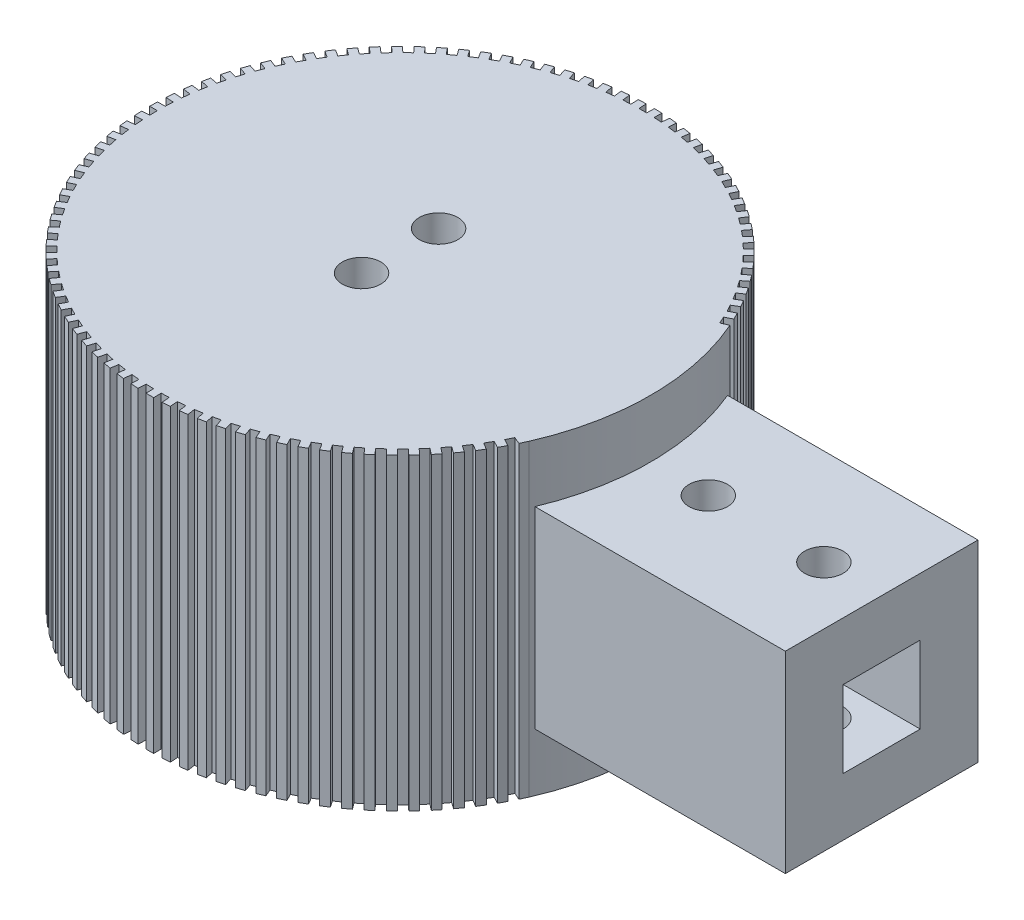
from build123d import *

# Parameters (mm, degrees)
SKETCH1_R               = 32.5
BOSS_EXTRUDE1_DEPTH     = 40
SKETCH2_W               = 10
SKETCH2_H               = 10
BOSS_EXTRUDE2_DEPTH     = 62.5
SKETCH3_R               = 2.5
CUT_EXTRUDE1_DEPTH      = 1
CUT_EXTRUDE1_DEPTH_BACK = 41
SKETCH4_R               = 2.5
CUT_EXTRUDE2_DEPTH      = 8.5
CUT_EXTRUDE2_DEPTH_BACK = 33.5
CUT_EXTRUDE3_DEPTH      = 41


with BuildPart() as part:
    # Sketch1 → Boss-Extrude1 (new body)
    with BuildSketch(Plane(origin=(0, 0, 0), x_dir=(1, 0, 0), z_dir=(0, 1, 0))):
        Circle(SKETCH1_R)
    extrude(amount=BOSS_EXTRUDE1_DEPTH)

    # Sketch2 → Boss-Extrude2 (add)
    with BuildSketch(Plane(origin=(0, 0, 0), x_dir=(0, 0, -1), z_dir=(1, 0, 0))):
        Polygon((0, 32.5), (-12.5, 32.5), (-12.5, 7.5), (12.5, 7.5), (12.5, 32.5), align=None)
        with Locations((0, 20)):
            Rectangle(SKETCH2_W, SKETCH2_H, mode=Mode.SUBTRACT)
    extrude(amount=BOSS_EXTRUDE2_DEPTH)

    # Sketch3 → Cut-Extrude1 (cut, two sides)
    with BuildSketch(Plane(origin=(0, 40, 0), x_dir=(1, 0, 0), z_dir=(0, 1, 0))) as cut_extrude1_sk:
        with Locations((0, 5)):
            Circle(SKETCH3_R)
        with Locations((0, -5)):
            Circle(SKETCH3_R)
    extrude(amount=CUT_EXTRUDE1_DEPTH, mode=Mode.SUBTRACT)
    extrude(cut_extrude1_sk.sketch, amount=-CUT_EXTRUDE1_DEPTH_BACK, mode=Mode.SUBTRACT)

    # Sketch4 → Cut-Extrude2 (cut, two sides)
    with BuildSketch(Plane(origin=(0, 32.5, 0), x_dir=(1, 0, 0), z_dir=(0, 1, 0))) as cut_extrude2_sk:
        with Locations((40, 0)):
            Circle(SKETCH4_R)
        with Locations((55, 0)):
            Circle(SKETCH4_R)
    extrude(amount=CUT_EXTRUDE2_DEPTH, mode=Mode.SUBTRACT)
    extrude(cut_extrude2_sk.sketch, amount=-CUT_EXTRUDE2_DEPTH_BACK, mode=Mode.SUBTRACT)

    # Sketch5 → Cut-Extrude3 (cut, through all)
    with BuildSketch(Plane(origin=(0, 40, 0), x_dir=(1, 0, 0), z_dir=(0, 1, 0))):
        with BuildLine():
            Line((-31.5, 0), (-32.494865573, 0))
            Line((-32.494865573, 0), (-32.479474882, 1))
            Line((-32.479474882, 1), (-31.484122983, 1))
            Line((-31.484122983, 1), (-31.436580309, 1.997853469))
            Line((-31.436580309, 1.997853469), (-32.429442895, 2.060951743))
            Line((-32.429442895, 2.060951743), (-32.350659271, 3.057962282))
            Line((-32.350659271, 3.057962282), (-31.357311338, 2.994833163))
            Line((-31.357311338, 2.994833163), (-31.246576604, 3.987662288))
            Line((-31.246576604, 3.987662288), (-32.233438297, 4.113604761))
            Line((-32.233438297, 4.113604761), (-32.091578973, 5.103611229))
            Line((-32.091578973, 5.103611229), (-31.104234867, 4.97760719))
            Line((-31.104234867, 4.97760719), (-30.930753964, 5.961414197))
            Line((-30.930753964, 5.961414197), (-31.90764102, 6.149693745))
            Line((-31.90764102, 6.149693745), (-31.703277214, 7.128709735))
            Line((-31.703277214, 7.128709735), (-30.725912621, 6.940338149))
            Line((-30.725912621, 6.940338149), (-30.490384094, 7.911161596))
            Line((-30.490384094, 7.911161596), (-31.453362933, 8.161020082))
            Line((-31.453362933, 8.161020082), (-31.187317547, 9.125103443))
            Line((-31.187317547, 9.125103443), (-30.223867969, 8.875122817))
            Line((-30.223867969, 8.875122817), (-29.927240209, 9.82905354))
            Line((-29.927240209, 9.82905354), (-30.872433255, 10.139484872))
            Line((-30.872433255, 10.139484872), (-30.545777559, 11.08475358))
            Line((-30.545777559, 11.08475358), (-29.600122468, 10.774170497))
            Line((-29.600122468, 10.774170497), (-29.24358989, 11.707367353))
            Line((-29.24358989, 11.707367353), (-30.167191185, 12.077121535))
            Line((-30.167191185, 12.077121535), (-29.781240506, 12.999769326))
            Line((-29.781240506, 12.999769326), (-28.857187721, 12.629834395))
            Line((-28.857187721, 12.629834395), (-28.442185956, 13.538539731))
            Line((-28.442185956, 13.538539731), (-29.340476484, 13.966127892))
            Line((-29.340476484, 13.966127892), (-28.896784908, 14.86243959))
            Line((-28.896784908, 14.86243959), (-27.998055264, 14.434642408))
            Line((-27.998055264, 14.434642408), (-27.526255378, 15.315197187))
            Line((-27.526255378, 15.315197187), (-28.395618039, 15.798897581))
            Line((-28.395618039, 15.798897581), (-27.895972157, 16.665264055))
            Line((-27.895972157, 16.665264055), (-27.02618452, 16.18132721))
            Line((-27.02618452, 16.18132721), (-26.499486284, 17.03018575))
            Line((-26.499486284, 17.03018575), (-27.336420462, 17.568050686))
            Line((-27.336420462, 17.568050686), (-26.782832171, 18.400983383))
            Line((-26.782832171, 18.400983383), (-25.94548887, 17.862855519))
            Line((-25.94548887, 17.862855519), (-25.366013112, 18.676599765))
            Line((-25.366013112, 18.676599765), (-26.167148768, 19.266463452))
            Line((-26.167148768, 19.266463452), (-25.561847173, 20.062608446))
            Line((-25.561847173, 20.062608446), (-24.760319893, 19.472456413))
            Line((-24.760319893, 19.472456413), (-24.130399958, 20.247809705))
            Line((-24.130399958, 20.247809705), (-24.892511202, 20.887296969))
            Line((-24.892511202, 20.887296969), (-24.237933639, 21.643448466))
            Line((-24.237933639, 21.643448466), (-23.475449848, 21.003648598))
            Line((-23.475449848, 21.003648598), (-22.7976222, 21.737488862))
            Line((-22.7976222, 21.737488862), (-23.517640279, 22.424024713))
            Line((-23.517640279, 22.424024713), (-22.8164225, 23.137137958))
            Line((-22.8164225, 23.137137958), (-22.096052451, 22.450266504))
            Line((-22.096052451, 22.450266504), (-21.373046464, 23.139638823))
            Line((-21.373046464, 23.139638823), (-22.048072118, 23.870458824))
            Line((-22.048072118, 23.870458824), (-21.303037681, 24.537662361))
            Line((-21.303037681, 24.537662361), (-20.62768205, 23.806485109))
            Line((-20.62768205, 23.806485109), (-19.862409013, 24.448613625))
            Line((-19.862409013, 24.448613625), (-20.489724153, 25.220775022))
            Line((-20.489724153, 25.220775022), (-19.703873048, 25.839382259))
            Line((-19.703873048, 25.839382259), (-19.076251253, 25.066843402))
            Line((-19.076251253, 25.066843402), (-18.271792651, 25.65914249))
            Line((-18.271792651, 25.65914249), (-18.848871301, 26.469536061))
            Line((-18.848871301, 26.469536061), (-18.025367872, 27.037056083))
            Line((-18.025367872, 27.037056083), (-17.448007126, 26.226266363))
            Line((-17.448007126, 26.226266363), (-16.60760223, 26.766351043))
            Line((-16.60760223, 26.766351043), (-17.132120697, 27.61171362))
            Line((-17.132120697, 27.61171362), (-16.274280902, 28.125861226))
            Line((-16.274280902, 28.125861226), (-15.749506032, 27.280085406))
            Line((-15.749506032, 27.280085406), (-14.876538855, 27.765780949))
            Line((-14.876538855, 27.765780949), (-15.346385089, 28.642708554))
            Line((-15.346385089, 28.642708554), (-14.457663147, 29.101413452))
            Line((-14.457663147, 29.101413452), (-13.987587236, 28.224057173))
            Line((-13.987587236, 28.224057173), (-13.08557291, 28.653407854))
            Line((-13.08557291, 28.653407854), (-13.498855004, 29.55836941))
            Line((-13.498855004, 29.55836941), (-12.582829485, 29.959784558))
            Line((-12.582829485, 29.959784558), (-12.169345363, 29.054380624))
            Line((-12.169345363, 29.054380624), (-11.24191598, 29.425657598))
            Line((-11.24191598, 29.425657598), (-11.596969795, 30.355009144))
            Line((-11.596969795, 30.355009144), (-10.65732921, 30.697518185))
            Line((-10.65732921, 30.697518185), (-10.302101831, 29.767712338))
            Line((-10.302101831, 29.767712338), (-9.352991823, 30.079420605))
            Line((-9.352991823, 30.079420605), (-9.648387682, 31.029419971))
            Line((-9.648387682, 31.029419971), (-8.688915631, 31.311643741))
            Line((-8.688915631, 31.311643741), (-8.393375372, 30.361179982))
            Line((-8.393375372, 30.361179982), (-7.426406469, 30.612064402))
            Line((-7.426406469, 30.612064402), (-7.660954917, 31.578886275))
            Line((-7.660954917, 31.578886275), (-6.685514856, 31.799688359))
            Line((-6.685514856, 31.799688359), (-6.450851752, 30.832393869))
            Line((-6.450851752, 30.832393869), (-5.469917597, 31.02144422))
            Line((-5.469917597, 31.02144422), (-5.64267419, 32.001195549))
            Line((-5.64267419, 32.001195549), (-4.655193872, 32.159686855))
            Line((-4.655193872, 32.159686855), (-4.482352828, 31.179456588))
            Line((-4.482352828, 31.179456588), (-3.491403297, 31.305911631))
            Line((-3.491403297, 31.305911631), (-3.601672406, 32.294647304))
            Line((-3.601672406, 32.294647304), (-2.606128065, 32.390189643))
            Line((-2.606128065, 32.390189643), (-2.495805052, 31.40097064))
            Line((-2.495805052, 31.40097064), (-1.498830348, 31.464321184))
            Line((-1.498830348, 31.464321184), (-1.546167958, 32.458059912))
            Line((-1.546167958, 32.458059912), (-0.546568301, 32.490268569))
            Line((-0.546568301, 32.490268569), (-0.49920755, 31.496044066))
            Line((-0.49920755, 31.496044066), (0.499777861, 31.496035022))
            Line((0.499777861, 31.496035022), (0.515562362, 32.490775368))
            Line((0.515562362, 32.490775368), (1.515192302, 32.459520651))
            Line((1.515192302, 32.459520651), (1.499400084, 31.464294039))
            Line((1.499400084, 31.464294039), (2.496373641, 31.400925442))
            Line((2.496373641, 31.400925442), (2.575216695, 32.39266194))
            Line((2.575216695, 32.39266194), (3.570851759, 32.298069699))
            Line((3.570851759, 32.298069699), (3.491970164, 31.305848405))
            Line((3.491970164, 31.305848405), (4.482917406, 31.179375419))
            Line((4.482917406, 31.179375419), (4.624501539, 32.164114695))
            Line((4.624501539, 32.164114695), (5.612132657, 32.006565821))
            Line((5.612132657, 32.006565821), (5.470479312, 31.021345169))
            Line((5.470479312, 31.021345169), (6.451410044, 30.832277056))
            Line((6.451410044, 30.832277056), (6.655165147, 31.806053912))
            Line((6.655165147, 31.806053912), (7.630815477, 31.586182798))
            Line((7.630815477, 31.586182798), (7.426960771, 30.611929924))
            Line((7.426960771, 30.611929924), (8.393925131, 30.361027995))
            Line((8.393925131, 30.361027995), (8.659030755, 31.319921376))
            Line((8.659030755, 31.319921376), (9.618771697, 31.038613365))
            Line((9.618771697, 31.038613365), (9.35353648, 30.079251242))
            Line((9.35353648, 30.079251242), (10.302640844, 29.76752579))
            Line((10.302640844, 29.76752579), (10.628029501, 30.70767457))
            Line((10.628029501, 30.70767457), (11.567996518, 30.366062391))
            Line((11.567996518, 30.366062391), (11.2424488, 29.425454032))
            Line((11.2424488, 29.425454032), (12.169871459, 29.054160264))
            Line((12.169871459, 29.054160264), (12.554232924, 29.971778797))
            Line((12.554232924, 29.971778797), (13.4706411, 29.571238002))
            Line((13.4706411, 29.571238002), (13.086091745, 28.653170904))
            Line((13.086091745, 28.653170904), (13.988098297, 28.22380389))
            Line((13.988098297, 28.22380389), (14.429884882, 29.11519725))
            Line((14.429884882, 29.11519725), (15.319044164, 28.657340674))
            Line((15.319044164, 28.657340674), (14.877041618, 27.765511569))
            Line((14.877041618, 27.765511569), (15.75, 27.279800219))
            Line((15.75, 27.279800219), (16.247432786, 28.141379079))
            Line((16.247432786, 28.141379079), (17.105762845, 27.628050349))
            Line((17.105762845, 27.628050349), (16.608086895, 26.766050319))
            Line((16.608086895, 26.766050319), (17.448482012, 26.225950421))
            Line((17.448482012, 26.225950421), (17.999558013, 27.054245506))
            Line((17.999558013, 27.054245506), (18.823602655, 26.487511617))
            Line((18.823602655, 26.487511617), (18.272257268, 25.658811631))
            Line((18.272257268, 25.658811631), (19.076705145, 25.066497977))
            Line((19.076705145, 25.066497977), (19.679205373, 25.858174036))
            Line((19.679205373, 25.858174036), (20.465646462, 25.240317024))
            Line((20.465646462, 25.240317024), (19.86285171, 24.448253965))
            Line((19.86285171, 24.448253965), (20.628113119, 23.806111592))
            Line((20.628113119, 23.806111592), (21.279611518, 24.557980825))
            Line((21.279611518, 24.557980825), (22.025282334, 23.891488583))
            Line((22.025282334, 23.891488583), (21.373465459, 23.139251809))
            Line((21.373465459, 23.139251809), (22.096458963, 22.449866398))
            Line((22.096458963, 22.449866398), (22.794332179, 23.158901293))
            Line((22.794332179, 23.158901293), (23.496230167, 22.44645755))
            Line((23.496230167, 22.44645755), (22.798015805, 21.737076053))
            Line((22.798015805, 21.737076053), (23.475830165, 21.003223516))
            Line((23.475830165, 21.003223516), (24.217268108, 21.66656904))
            Line((24.217268108, 21.66656904), (24.872566974, 20.911042554))
            Line((24.872566974, 20.911042554), (24.130766589, 20.247372764))
            Line((24.130766589, 20.247372764), (24.760672484, 19.472008066))
            Line((24.760672484, 19.472008066), (25.542689647, 20.08699316))
            Line((25.542689647, 20.08699316), (26.148750733, 19.291426171))
            Line((26.148750733, 19.291426171), (25.366351292, 18.67614045))
            Line((25.366351292, 18.67614045), (25.945812315, 17.862385712))
            Line((25.945812315, 17.862385712), (26.765259789, 18.426534048))
            Line((26.765259789, 18.426534048), (27.319642701, 17.594130023))
            Line((27.319642701, 17.594130023), (26.499794652, 17.029705911))
            Line((26.499794652, 17.029705911), (27.026477517, 16.180837835))
            Line((27.026477517, 16.180837835), (27.880055677, 16.691877787))
            Line((27.880055677, 16.691877787), (28.380528111, 15.825988524))
            Line((28.380528111, 15.825988524), (27.526532691, 15.314698757))
            Line((27.526532691, 15.314698757), (27.998316633, 14.434135434))
            Line((27.998316633, 14.434135434), (28.88258842, 14.890009225))
            Line((28.88258842, 14.890009225), (29.32713515, 13.994121354))
            Line((29.32713515, 13.994121354), (28.442431099, 13.538024715))
            Line((28.442431099, 13.538024715), (28.857416409, 12.629311865))
            Line((28.857416409, 12.629311865), (29.768821174, 13.028183852))
            Line((29.768821174, 13.028183852), (34.69584289, 15.184471613))
            ThreePointArc((34.69584289, 15.184471613), (-37.873073443, 0), (34.69584289, -15.184471613))
            Line((34.69584289, -15.184471613), (29.768821174, -13.028183852))
            Line((29.768821174, -13.028183852), (29.353791097, -13.938121711))
            Line((29.353791097, -13.938121711), (28.441940804, -13.539054742))
            Line((28.441940804, -13.539054742), (27.998316633, -14.434135434))
            Line((27.998316633, -14.434135434), (28.88258842, -14.890009225))
            Line((28.88258842, -14.890009225), (28.410682107, -15.771792251))
            Line((28.410682107, -15.771792251), (27.525978055, -15.315695613))
            Line((27.525978055, -15.315695613), (27.026477517, -16.180837835))
            Line((27.026477517, -16.180837835), (27.880055677, -16.691877787))
            Line((27.880055677, -16.691877787), (27.353173327, -17.54195535))
            Line((27.353173327, -17.54195535), (26.499177908, -17.030665583))
            Line((26.499177908, -17.030665583), (25.945812315, -17.862385712))
            Line((25.945812315, -17.862385712), (26.765259789, -18.426534048))
            Line((26.765259789, -18.426534048), (26.185522973, -19.241483186))
            Line((26.185522973, -19.241483186), (25.365674924, -18.677059074))
            Line((25.365674924, -18.677059074), (24.760672484, -19.472008066))
            Line((24.760672484, -19.472008066), (25.542689647, -20.08699316))
            Line((25.542689647, -20.08699316), (24.91243276, -20.863532361))
            Line((24.91243276, -20.863532361), (24.13003332, -20.24824664))
            Line((24.13003332, -20.24824664), (23.475830165, -21.003223516))
            Line((23.475830165, -21.003223516), (24.217268108, -21.66656904))
            Line((24.217268108, -21.66656904), (23.539028973, -22.401571454))
            Line((23.539028973, -22.401571454), (22.797228588, -21.737901663))
            Line((22.797228588, -21.737901663), (22.096458963, -22.449866398))
            Line((22.096458963, -22.449866398), (22.794332179, -23.158901293))
            Line((22.794332179, -23.158901293), (22.070841824, -23.849407325))
            Line((22.070841824, -23.849407325), (21.372627463, -23.140025829))
            Line((21.372627463, -23.140025829), (20.628113119, -23.806111592))
            Line((20.628113119, -23.806111592), (21.279611518, -24.557980825))
            Line((21.279611518, -24.557980825), (20.513783185, -25.201210051))
            Line((20.513783185, -25.201210051), (19.86196631, -24.448973277))
            Line((19.86196631, -24.448973277), (19.076705145, -25.066497977))
            Line((19.076705145, -25.066497977), (19.679205373, -25.858174036))
            Line((19.679205373, -25.858174036), (18.874122781, -26.451536398))
            Line((18.874122781, -26.451536398), (18.271328029, -25.659473339))
            Line((18.271328029, -25.659473339), (17.448482012, -26.225950421))
            Line((17.448482012, -26.225950421), (17.999558013, -27.054245506))
            Line((17.999558013, -27.054245506), (17.158462946, -27.595351745))
            Line((17.158462946, -27.595351745), (16.607117559, -26.766651759))
            Line((16.607117559, -26.766651759), (15.75, -27.279800219))
            Line((15.75, -27.279800219), (16.247432786, -28.141379079))
            Line((16.247432786, -28.141379079), (15.373712037, -28.628050349))
            Line((15.373712037, -28.628050349), (14.876036088, -27.766050319))
            Line((14.876036088, -27.766050319), (13.988098297, -28.22380389))
            Line((13.988098297, -28.22380389), (14.429884882, -29.11519725))
            Line((14.429884882, -29.11519725), (13.527056616, -29.545473899))
            Line((13.527056616, -29.545473899), (13.08505407, -28.653644794))
            Line((13.08505407, -28.653644794), (12.169871459, -29.054160264))
            Line((12.169871459, -29.054160264), (12.554232924, -29.971778797))
            Line((12.554232924, -29.971778797), (11.625932511, -30.343928253))
            Line((11.625932511, -30.343928253), (11.241383157, -29.425861155))
            Line((11.241383157, -29.425861155), (10.302640845, -29.76752579))
            Line((10.302640845, -29.76752579), (10.628029501, -30.70767457))
            Line((10.628029501, -30.70767457), (9.67799488, -31.020198318))
            Line((9.67799488, -31.020198318), (9.352447162, -30.079589959))
            Line((9.352447162, -30.079589959), (8.393925131, -30.361027995))
            Line((8.393925131, -30.361027995), (8.659030755, -31.319921376))
            Line((8.659030755, -31.319921376), (7.69108738, -31.571560993))
            Line((7.69108738, -31.571560993), (7.425852163, -30.61219887))
            Line((7.425852163, -30.61219887), (6.451410044, -30.832277056))
            Line((6.451410044, -30.832277056), (6.655165147, -31.806053912))
            Line((6.655165147, -31.806053912), (5.673210585, -31.995796134))
            Line((5.673210585, -31.995796134), (5.469355879, -31.021543261))
            Line((5.469355879, -31.021543261), (4.482917406, -31.179375419))
            Line((4.482917406, -31.179375419), (4.624501539, -32.164114695))
            Line((4.624501539, -32.164114695), (3.632489773, -32.291195497))
            Line((3.632489773, -32.291195497), (3.490836429, -31.305974846))
            Line((3.490836429, -31.305974846), (2.496373641, -31.400925442))
            Line((2.496373641, -31.400925442), (2.575216695, -32.39266194))
            Line((2.575216695, -32.39266194), (1.577142207, -32.456569613))
            Line((1.577142207, -32.456569613), (1.498260612, -31.464348319))
            Line((1.498260612, -31.464348319), (0.499777861, -31.496035022))
            Line((0.499777861, -31.496035022), (0.515562362, -32.490775368))
            Line((0.515562362, -32.490775368), (-0.484555954, -32.491252578))
            Line((-0.484555954, -32.491252578), (-0.500348171, -31.496025967))
            Line((-0.500348171, -31.496025967), (-1.498830348, -31.464321184))
            Line((-1.498830348, -31.464321184), (-1.546167958, -32.458059912))
            Line((-1.546167958, -32.458059912), (-2.544302979, -32.395104737))
            Line((-2.544302979, -32.395104737), (-2.496942229, -31.400880235))
            Line((-2.496942229, -31.400880235), (-3.491403297, -31.305911631))
            Line((-3.491403297, -31.305911631), (-3.601672406, -32.294647304))
            Line((-3.601672406, -32.294647304), (-4.593804994, -32.168513243))
            Line((-4.593804994, -32.168513243), (-4.483481981, -31.17929424))
            Line((-4.483481981, -31.17929424), (-5.469917597, -31.02144422))
            Line((-5.469917597, -31.02144422), (-5.64267419, -32.001195549))
            Line((-5.64267419, -32.001195549), (-6.624809378, -31.8123905))
            Line((-6.624809378, -31.8123905), (-6.451968334, -30.832160233))
            Line((-6.451968334, -30.832160233), (-7.426406469, -30.612064402))
            Line((-7.426406469, -30.612064402), (-7.660954917, -31.578886275))
            Line((-7.660954917, -31.578886275), (-8.629137992, -31.328170488))
            Line((-8.629137992, -31.328170488), (-8.394474888, -30.360875998))
            Line((-8.394474888, -30.360875998), (-9.352991823, -30.079420605))
            Line((-9.352991823, -30.079420605), (-9.648387682, -31.029419971))
            Line((-9.648387682, -31.029419971), (-10.598720114, -30.71780299))
            Line((-10.598720114, -30.71780299), (-10.303179854, -29.767339231))
            Line((-10.303179854, -29.767339231), (-11.24191598, -29.425657598))
            Line((-11.24191598, -29.425657598), (-11.596969795, -30.355009144))
            Line((-11.596969795, -30.355009144), (-12.52562493, -29.983745742))
            Line((-12.52562493, -29.983745742), (-12.170397552, -29.053939895))
            Line((-12.170397552, -29.053939895), (-13.08557291, -28.653407854))
            Line((-13.08557291, -28.653407854), (-13.498855004, -29.55836941))
            Line((-13.498855004, -29.55836941), (-14.402093476, -29.128954532))
            Line((-14.402093476, -29.128954532), (-13.988609354, -28.223550598))
            Line((-13.988609354, -28.223550598), (-14.876538855, -27.765780949))
            Line((-14.876538855, -27.765780949), (-15.346385089, -28.642708554))
            Line((-15.346385089, -28.642708554), (-16.220569874, -28.156871303))
            Line((-16.220569874, -28.156871303), (-15.750493963, -27.279515024))
            Line((-15.750493963, -27.279515024), (-16.60760223, -26.766351043))
            Line((-16.60760223, -26.766351043), (-17.132120697, -27.61171362))
            Line((-17.132120697, -27.61171362), (-17.973731762, -27.071410291))
            Line((-17.973731762, -27.071410291), (-17.448956892, -26.225634471))
            Line((-17.448956892, -26.225634471), (-18.271792651, -25.65914249))
            Line((-18.271792651, -25.65914249), (-18.848871301, -26.469536061))
            Line((-18.848871301, -26.469536061), (-19.654519776, -25.876942264))
            Line((-19.654519776, -25.876942264), (-19.07715903, -25.066152544))
            Line((-19.07715903, -25.066152544), (-19.862409013, -24.448613625))
            Line((-19.862409013, -24.448613625), (-20.489724153, -25.220775022))
            Line((-20.489724153, -25.220775022), (-21.256165976, -24.578276924))
            Line((-21.256165976, -24.578276924), (-20.628544182, -23.805738067))
            Line((-20.628544182, -23.805738067), (-21.373046464, -23.139638823))
            Line((-21.373046464, -23.139638823), (-22.048072118, -23.870458824))
            Line((-22.048072118, -23.870458824), (-22.772221098, -23.180643538))
            Line((-22.772221098, -23.180643538), (-22.096865467, -22.449466286))
            Line((-22.096865467, -22.449466286), (-22.7976222, -21.737488862))
            Line((-22.7976222, -21.737488862), (-23.517640279, -22.424024713))
            Line((-23.517640279, -22.424024713), (-24.196580523, -21.689669882))
            Line((-24.196580523, -21.689669882), (-23.476210474, -21.002798427))
            Line((-23.476210474, -21.002798427), (-24.130399958, -20.247809705))
            Line((-24.130399958, -20.247809705), (-24.892511202, -20.887296969))
            Line((-24.892511202, -20.887296969), (-25.523508858, -20.11135958))
            Line((-25.523508858, -20.11135958), (-24.761025067, -19.471559712))
            Line((-24.761025067, -19.471559712), (-25.366013112, -18.676599765))
            Line((-25.366013112, -18.676599765), (-26.167148768, -19.266463452))
            Line((-26.167148768, -19.266463452), (-26.747663031, -18.452067931))
            Line((-26.747663031, -18.452067931), (-25.946135752, -17.861915898))
            Line((-25.946135752, -17.861915898), (-26.499486284, -17.03018575))
            Line((-26.499486284, -17.03018575), (-27.336420462, -17.568050686))
            Line((-27.336420462, -17.568050686), (-27.864113806, -16.718476318))
            Line((-27.864113806, -16.718476318), (-27.026770505, -16.180348453))
            Line((-27.026770505, -16.180348453), (-27.526255378, -15.315197187))
            Line((-27.526255378, -15.315197187), (-28.395618039, -15.798897581))
            Line((-28.395618039, -15.798897581), (-28.868365629, -14.917565301))
            Line((-28.868365629, -14.917565301), (-27.998577992, -14.433628456))
            Line((-27.998577992, -14.433628456), (-28.442185956, -13.538539731))
            Line((-28.442185956, -13.538539731), (-29.340476484, -13.966127892))
            Line((-29.340476484, -13.966127892), (-29.756374732, -13.056586513))
            Line((-29.756374732, -13.056586513), (-28.857645088, -12.628789331))
            Line((-28.857645088, -12.628789331), (-29.24358989, -11.707367353))
            Line((-29.24358989, -11.707367353), (-30.167191185, -12.077121535))
            Line((-30.167191185, -12.077121535), (-30.524565417, -11.14303346))
            Line((-30.524565417, -11.14303346), (-29.600512632, -10.773098529))
            Line((-29.600512632, -10.773098529), (-29.927240209, -9.82905354))
            Line((-29.927240209, -9.82905354), (-30.872433255, -10.139484872))
            Line((-30.872433255, -10.139484872), (-31.16984445, -9.184611344))
            Line((-31.16984445, -9.184611344), (-30.224189359, -8.874028261))
            Line((-30.224189359, -8.874028261), (-30.490384094, -7.911161596))
            Line((-30.490384094, -7.911161596), (-31.453362933, -8.161020082))
            Line((-31.453362933, -8.161020082), (-31.689613521, -7.18920604))
            Line((-31.689613521, -7.18920604), (-30.726163943, -6.939225414))
            Line((-30.726163943, -6.939225414), (-30.930753964, -5.961414197))
            Line((-30.930753964, -5.961414197), (-31.90764102, -6.149693745))
            Line((-31.90764102, -6.149693745), (-32.081779703, -5.16485234))
            Line((-32.081779703, -5.16485234), (-31.104415109, -4.976480755))
            Line((-31.104415109, -4.976480755), (-31.246576604, -3.987662288))
            Line((-31.246576604, -3.987662288), (-32.233438297, -4.113604761))
            Line((-32.233438297, -4.113604761), (-32.344763881, -3.119701603))
            Line((-32.344763881, -3.119701603), (-31.357419774, -2.993697564))
            Line((-31.357419774, -2.993697564), (-31.436580309, -1.997853469))
            Line((-31.436580309, -1.997853469), (-32.429442895, -2.060951743))
            Line((-32.429442895, -2.060951743), (-32.47750711, -1.061988929))
            Line((-32.47750711, -1.061988929), (-31.484159177, -0.99885981))
            Line((-31.484159177, -0.99885981), (-31.5, 0))
        make_face()
    extrude(amount=-CUT_EXTRUDE3_DEPTH, mode=Mode.SUBTRACT)


solid = part.part
